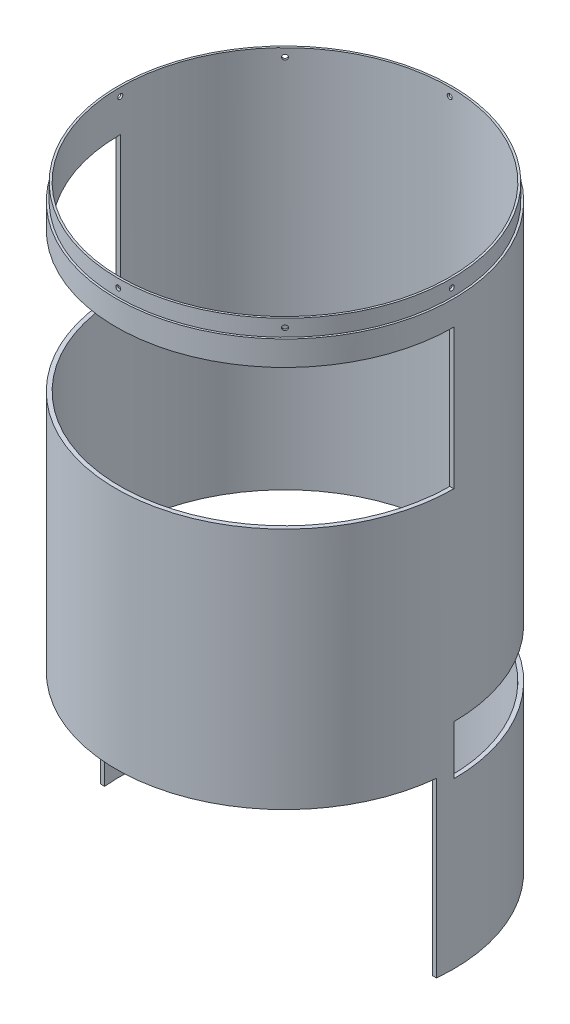
from build123d import *
from build123d.topology import SkipClean

# Parameters (mm, degrees)
SKETCH1_R           = 205
BOSS_EXTRUDE1_DEPTH = 705
CUT_EXTRUDE14_DEPTH = 210
SHELL1_T            = -5
CUT_EXTRUDE15_DEPTH = 170
CUT_EXTRUDE16_DEPTH = 60
SKETCH22_R          = 202.5
SKETCH22_R_2        = 200
BOSS_EXTRUDE4_DEPTH = 20
SKETCH26_R          = 3
CUT_EXTRUDE18_DEPTH = 781.81687994
CIRPATTERN1_COUNT   = 4
CIRPATTERN1_ANGLE   = 135


with BuildPart() as part:
    # Sketch1 → Boss-Extrude1 (new body)
    with BuildSketch(Plane(origin=(0, 0, 0), x_dir=(1, 0, 0), z_dir=(0, 1, 0))):
        with Locations(Location((0, 0, 0), (0, 0, 270))):
            Circle(SKETCH1_R)
    extrude(amount=BOSS_EXTRUDE1_DEPTH)

    # Sketch17 → Cut-Extrude14 (cut)
    with BuildSketch(Plane(origin=(0, 0, 0), x_dir=(1, 0, 0), z_dir=(0, 1, 0))):
        with BuildLine():
            Line((-204.022057631, -20), (204.022057631, -20))
            ThreePointArc((204.022057631, -20), (0, -205), (-204.022057631, -20))
        make_face()
    extrude(amount=CUT_EXTRUDE14_DEPTH, mode=Mode.SUBTRACT)

    # Shell1
    shell1_openings = [part.faces().sort_by_distance(p)[0] for p in [
        (0, 705, 0),
        (0, 105, 20),
        (0, 210, 97.908161043),
        (0, 0, -76.302369803),
    ]]
    offset(amount=SHELL1_T, openings=shell1_openings)

    # Sketch18 → Cut-Extrude15 (cut)
    with BuildSketch(Plane(origin=(0, 675, 0), x_dir=(1, 0, 0), z_dir=(0, 1, 0))):
        with BuildLine():
            Line((-205, 0), (205, 0))
            ThreePointArc((205, 0), (0, -205), (-205, 0))
        make_face()
    extrude(amount=-CUT_EXTRUDE15_DEPTH, mode=Mode.SUBTRACT)

    # Sketch19 → Cut-Extrude16 (cut)
    with BuildSketch(Plane(origin=(0, 260, 0), x_dir=(-1, 0, 0), z_dir=(0, -1, 0))):
        with BuildLine():
            Line((-205, 0), (205, 0))
            ThreePointArc((205, 0), (0, 205), (-205, 0))
        make_face()
    extrude(amount=CUT_EXTRUDE16_DEPTH, mode=Mode.SUBTRACT)

    # Sketch22 → Boss-Extrude4 (add)
    with BuildSketch(Plane(origin=(0, 705, 0), x_dir=(1, 0, 0), z_dir=(0, 1, 0))):
        with Locations(Location((0, 0, 0), (0, 0, 270))):
            Circle(SKETCH22_R)
        with Locations(Location((0, 0, 0), (0, 0, 354.260829523))):
            Circle(SKETCH22_R_2, mode=Mode.SUBTRACT)
    extrude(amount=BOSS_EXTRUDE4_DEPTH)

    # Sketch26 → Cut-Extrude18 (cut, symmetric)
    with SkipClean():  # the faces are left unmerged after this step: merging them gives an invalid solid
        with BuildSketch(Plane.XY):
            with Locations((0, 715)):
                Circle(SKETCH26_R)
        cut_extrude18 = extrude(amount=CUT_EXTRUDE18_DEPTH, both=True, mode=Mode.SUBTRACT)

    # CirPattern1: Cut-Extrude18 ×4 about axis
    with SkipClean():  # the faces are left unmerged after this step: merging them gives an invalid solid
        cirpattern1_axis = Axis((0, 832.537864543, 0), (0, -1, 0))
        for i in range(1, CIRPATTERN1_COUNT):
            add(cut_extrude18.rotate(cirpattern1_axis, i * CIRPATTERN1_ANGLE / (CIRPATTERN1_COUNT - 1)), mode=Mode.SUBTRACT)


solid = part.part
